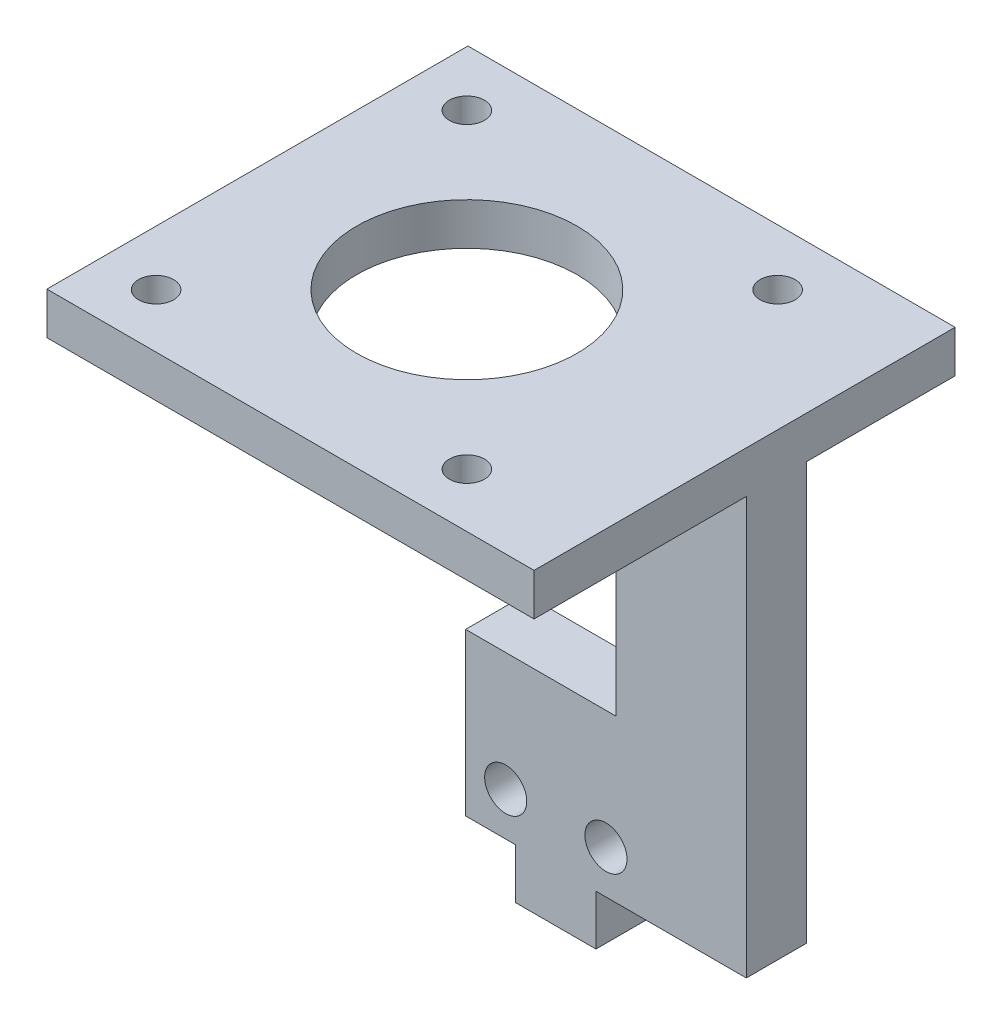
from build123d import *

# Parameters (mm, degrees)
SKETCH_1_W          = 18
SKETCH_1_H          = 50
EXTRUDE_1_DEPTH     = 6
SKETCH_3_R          = 2.1
CUT_EXTRUDE_2_DEPTH = 6
SKETCH_4_W          = 8
SKETCH_4_H          = 10
EXTRUDE_2_DEPTH     = 5
SKETCH_5_W          = 6
SKETCH_5_H          = 50
EXTRUDE_3_DEPTH     = 10
SKETCH_6_W          = 15
SKETCH_6_H          = 33.880633875
CUT_EXTRUDE_3_DEPTH = 10
SKETCH_7_W          = 18.194641251
SKETCH_7_H          = 8.438338953
CUT_EXTRUDE_4_DEPTH = 4.2
SKETCH_8_W          = 58.547266504
SKETCH_8_H          = 42
EXTRUDE_4_DEPTH     = 4.2
SKETCH_9_W          = 49.225807408
SKETCH_9_H          = 6.051517764
CUT_EXTRUDE_5_DEPTH = 9.95
SKETCH_15_R         = 1.75
CUT_EXTRUDE_6_DEPTH = 9.95
SKETCH_16_R         = 11
CUT_EXTRUDE_7_DEPTH = 10


with BuildPart() as part:
    # 草图1 → 凸台-拉伸1 (new body)
    with BuildSketch(Plane.XY):
        with Locations((9, 25)):
            Rectangle(SKETCH_1_W, SKETCH_1_H)
    extrude(amount=EXTRUDE_1_DEPTH)

    # 草图3 → 切除-拉伸2 (cut)
    with BuildSketch(Plane.XY.offset(6)):
        with Locations((4, 4.30447472)):
            Circle(SKETCH_3_R)
        with Locations((14, 4.30447472)):
            Circle(SKETCH_3_R)
    extrude(amount=-CUT_EXTRUDE_2_DEPTH, mode=Mode.SUBTRACT)

    # 草图4 → 凸台-拉伸2 (add)
    with BuildSketch(Plane.XZ):
        with Locations((9, 1)):
            Rectangle(SKETCH_4_W, SKETCH_4_H)
    extrude(amount=EXTRUDE_2_DEPTH)

    # 草图5 → 凸台-拉伸3 (add)
    with BuildSketch(Plane(origin=(18, 0, 0), x_dir=(0, 0, -1), z_dir=(1, 0, 0))):
        with Locations((-3, 25)):
            Rectangle(SKETCH_5_W, SKETCH_5_H)
    extrude(amount=EXTRUDE_3_DEPTH)

    # 草图6 → 切除-拉伸3 (cut)
    with BuildSketch(Plane.XY.offset(6)):
        with Locations((7.5, 33.059683062)):
            Rectangle(SKETCH_6_W, SKETCH_6_H)
    extrude(amount=-CUT_EXTRUDE_3_DEPTH, mode=Mode.SUBTRACT)

    # 草图7 → 切除-拉伸4 (cut)
    with BuildSketch(Plane(origin=(0, 50, 0), x_dir=(1, 0, 0), z_dir=(0, 1, 0))):
        with Locations((18.902679374, -1.780830523)):
            Rectangle(SKETCH_7_W, SKETCH_7_H)
    extrude(amount=-CUT_EXTRUDE_4_DEPTH, mode=Mode.SUBTRACT)

    # 草图8 → 凸台-拉伸4 (add)
    with BuildSketch(Plane(origin=(0, 45.8, 0), x_dir=(1, 0, 0), z_dir=(0, 1, 0))):
        with Locations((-1.273633252, -6.17)):
            Rectangle(SKETCH_8_W, SKETCH_8_H)
    extrude(amount=-EXTRUDE_4_DEPTH)

    # 草图9 → 切除-拉伸5 (cut)
    with BuildSketch(Plane.ZY.offset(30.547266504)):
        with Locations((2.557096296, 42.774241118)):
            Rectangle(SKETCH_9_W, SKETCH_9_H)
    extrude(amount=-CUT_EXTRUDE_5_DEPTH, mode=Mode.SUBTRACT)

    # 草图15 → 切除-拉伸6 (cut)
    with BuildSketch(Plane.XZ.offset(-41.6)):
        with Locations((15.90237217, -9.22379542)):
            Circle(SKETCH_15_R)
        with Locations((-15.09762783, -9.22379542)):
            Circle(SKETCH_15_R)
        with Locations((15.90237217, 21.77620458)):
            Circle(SKETCH_15_R)
        with Locations((-15.09762783, 21.77620458)):
            Circle(SKETCH_15_R)
    extrude(amount=-CUT_EXTRUDE_6_DEPTH, mode=Mode.SUBTRACT)

    # 草图16 → 切除-拉伸7 (cut)
    with BuildSketch(Plane.XZ.offset(-41.6)):
        with Locations((0.40237217, 6.27620458)):
            Circle(SKETCH_16_R)
    extrude(amount=-CUT_EXTRUDE_7_DEPTH, mode=Mode.SUBTRACT)


solid = part.part
